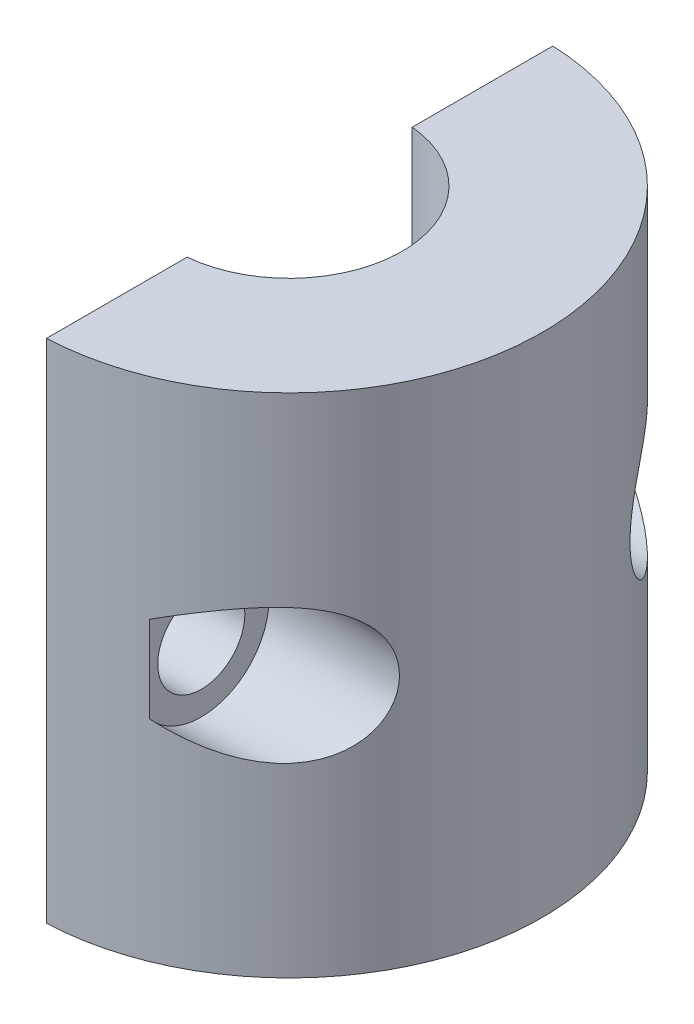
from build123d import *

# Parameters (mm, degrees)
BOSS_EXTRUDE1_DEPTH = 19.05
SKETCH4_R           = 1.6383
CUT_EXTRUDE1_DEPTH  = 4.175
SKETCH5_R           = 2.54
CUT_EXTRUDE2_DEPTH  = 6.953125


with BuildPart() as part:
    # Sketch1 → Boss-Extrude1 (new body)
    with BuildSketch(Plane(origin=(0, 0, 0), x_dir=(1, 0, 0), z_dir=(0, 1, 0))):
        with BuildLine():
            Line((0.396875, 9.516728179), (0.396875, 4.231428864))
            ThreePointArc((0.396875, 4.231428864), (4.25, 0), (0.396875, -4.231428864))
            Line((0.396875, -4.231428864), (0.396875, -9.516728179))
            ThreePointArc((0.396875, -9.516728179), (9.525, 0), (0.396875, 9.516728179))
        make_face()
    extrude(amount=BOSS_EXTRUDE1_DEPTH)

    # Sketch4 → Cut-Extrude1 (cut, through all)
    with BuildSketch(Plane(origin=(3.571875, 0, 0), x_dir=(0, 0, -1), z_dir=(1, 0, 0))):
        with Locations((-6.874078522, 9.525)):
            Circle(SKETCH4_R)
    cut_extrude1 = extrude(amount=-CUT_EXTRUDE1_DEPTH, mode=Mode.SUBTRACT)

    # Sketch5 → Cut-Extrude2 (cut, through all)
    with BuildSketch(Plane(origin=(3.571875, 0, 0), x_dir=(0, 0, -1), z_dir=(1, 0, 0))):
        with Locations((-6.874078522, 9.525)):
            Circle(SKETCH5_R)
    cut_extrude2 = extrude(amount=CUT_EXTRUDE2_DEPTH, mode=Mode.SUBTRACT)

    # Mirror1: Cut-Extrude1, Cut-Extrude2 across plane
    add(cut_extrude1.mirror(Plane.XY), mode=Mode.SUBTRACT)
    add(cut_extrude2.mirror(Plane.XY), mode=Mode.SUBTRACT)


solid = part.part
